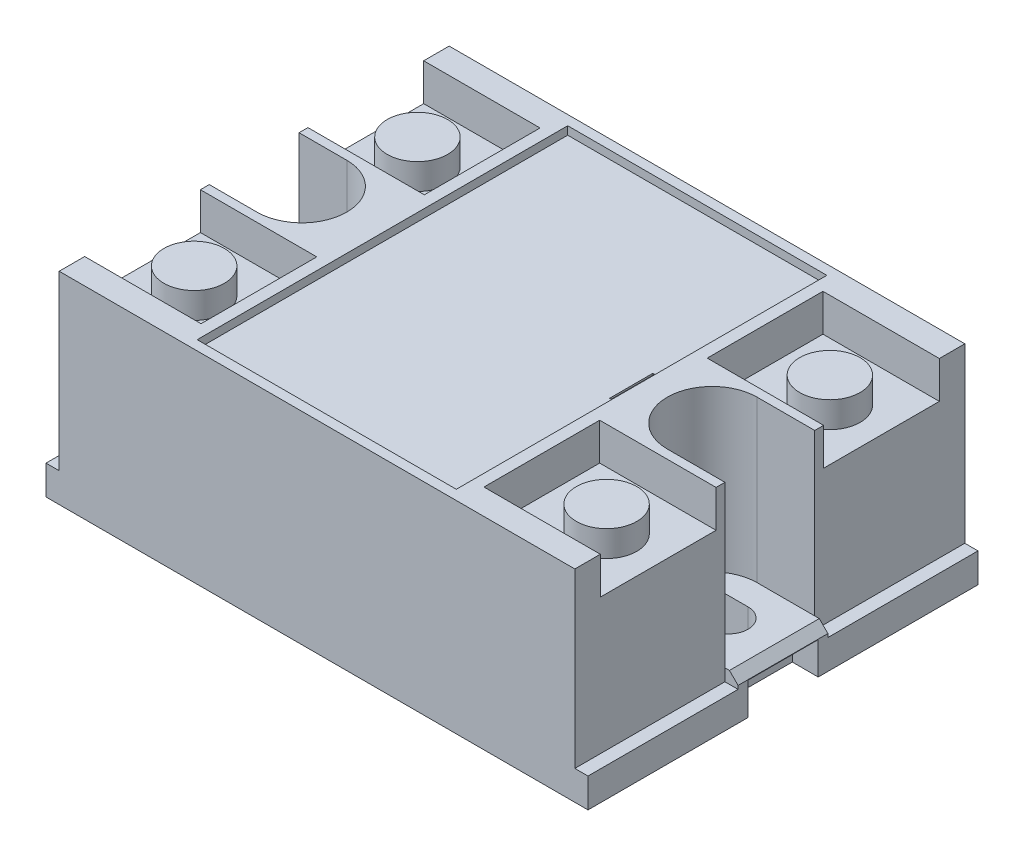
from build123d import *

# Parameters (mm, degrees)
SKETCH1_W                    = 62.75
SKETCH1_H                    = 45.15
BOSS_EXTRUDE1_DEPTH          = 23.4
SKETCH2_W                    = 30
SKETCH2_H                    = 42.9
CUT_EXTRUDE1_DEPTH           = 0.95
SKETCH3_W                    = 15
SKETCH3_H                    = 13.4
CUT_EXTRUDE2_DEPTH           = 4.3
SKETCH4_R                    = 3.5
BOSS_EXTRUDE2_DEPTH          = 3
CUT_EXTRUDE3_DEPTH           = 18.6
SKETCH6_W                    = 0.2
SKETCH6_H                    = 5
CUT_EXTRUDE_THIN1_DEPTH      = 1.95
CUT_EXTRUDE_THIN1_DEPTH_BACK = 1
CUT_EXTRUDE4_DEPTH           = 5.8
SKETCH8_R                    = 2.25
CUT_EXTRUDE5_DEPTH           = 5.8
SKETCH9_W                    = 1.525
SKETCH9_H                    = 45.15
CUT_EXTRUDE6_DEPTH           = 20
SKETCH11_W                   = 1.525
SKETCH11_H                   = 10.4
BOSS_EXTRUDE3_DEPTH          = 1.4
CHAMFER1_SIZE                = 1
SKETCH10_W                   = 3
SKETCH10_H                   = 8.15
CUT_EXTRUDE7_DEPTH           = 3.75


with BuildPart() as part:
    # Sketch1 → Boss-Extrude1 (new body)
    with BuildSketch(Plane(origin=(0, 0, 0), x_dir=(1, 0, 0), z_dir=(0, 1, 0))):
        Rectangle(SKETCH1_W, SKETCH1_H)
    extrude(amount=BOSS_EXTRUDE1_DEPTH)

    # Sketch2 → Cut-Extrude1 (cut)
    with BuildSketch(Plane(origin=(0, 23.4, 0), x_dir=(1, 0, 0), z_dir=(0, 1, 0))):
        Rectangle(SKETCH2_W, SKETCH2_H)
    extrude(amount=-CUT_EXTRUDE1_DEPTH, mode=Mode.SUBTRACT)

    # Sketch3 → Cut-Extrude2 (cut)
    with BuildSketch(Plane(origin=(0, 23.4, 0), x_dir=(1, 0, 0), z_dir=(0, 1, 0))):
        with Locations((-23.875, 12.925)):
            Rectangle(SKETCH3_W, SKETCH3_H)
        with Locations((-23.875, -12.925)):
            Rectangle(SKETCH3_W, SKETCH3_H)
        with Locations((23.875, -12.925)):
            Rectangle(SKETCH3_W, SKETCH3_H)
        with Locations((23.875, 12.925)):
            Rectangle(SKETCH3_W, SKETCH3_H)
    extrude(amount=-CUT_EXTRUDE2_DEPTH, mode=Mode.SUBTRACT)

    # Sketch4 → Boss-Extrude2 (add)
    with BuildSketch(Plane(origin=(0, 19.1, 0), x_dir=(1, 0, 0), z_dir=(0, 1, 0))):
        with Locations((-23.875, 12.925)):
            Circle(SKETCH4_R)
        with Locations((-23.875, -12.925)):
            Circle(SKETCH4_R)
        with Locations((23.875, -12.925)):
            Circle(SKETCH4_R)
        with Locations((23.875, 12.925)):
            Circle(SKETCH4_R)
    extrude(amount=BOSS_EXTRUDE2_DEPTH)

    # Sketch5 → Cut-Extrude3 (cut)
    with BuildSketch(Plane(origin=(0, 23.4, 0), x_dir=(1, 0, 0), z_dir=(0, 1, 0))):
        with BuildLine():
            Line((31.375, -5.2), (23.175, -5.2))
            ThreePointArc((23.175, -5.2), (17.975, 0), (23.175, 5.2))
            Line((23.175, 5.2), (31.375, 5.2))
            ThreePointArc((31.375, 5.2), (36.575, 0), (31.375, -5.2))
        make_face()
        with BuildLine():
            Line((-31.375, 5.2), (-24.325, 5.2))
            ThreePointArc((-24.325, 5.2), (-19.125, 0), (-24.325, -5.2))
            Line((-24.325, -5.2), (-31.375, -5.2))
            ThreePointArc((-31.375, -5.2), (-36.575, 0), (-31.375, 5.2))
        make_face()
    extrude(amount=-CUT_EXTRUDE3_DEPTH, mode=Mode.SUBTRACT)

    # Sketch6 → Cut-Extrude-Thin1 (cut, two sides)
    with BuildSketch(Plane(origin=(0, 22.45, 0), x_dir=(1, 0, 0), z_dir=(0, 1, 0))) as cut_extrude_thin1_sk:
        with Locations((13.9, 0)):
            Rectangle(SKETCH6_W, SKETCH6_H)
    extrude(amount=CUT_EXTRUDE_THIN1_DEPTH, mode=Mode.SUBTRACT)
    extrude(cut_extrude_thin1_sk.sketch, amount=-CUT_EXTRUDE_THIN1_DEPTH_BACK, mode=Mode.SUBTRACT)

    # Sketch7 → Cut-Extrude4 (cut, through all)
    with BuildSketch(Plane(origin=(0, 4.8, 0), x_dir=(1, 0, 0), z_dir=(0, 1, 0))):
        with BuildLine():
            Line((22.275, 2.25), (25.075, 2.25))
            ThreePointArc((25.075, 2.25), (27.325, 0), (25.075, -2.25))
            Line((25.075, -2.25), (22.275, -2.25))
            ThreePointArc((22.275, -2.25), (20.025, 0), (22.275, 2.25))
        make_face()
    extrude(amount=-CUT_EXTRUDE4_DEPTH, mode=Mode.SUBTRACT)

    # Sketch8 → Cut-Extrude5 (cut, through all)
    with BuildSketch(Plane(origin=(0, 4.8, 0), x_dir=(1, 0, 0), z_dir=(0, 1, 0))):
        with Locations((-23.825, 0)):
            Circle(SKETCH8_R)
    extrude(amount=-CUT_EXTRUDE5_DEPTH, mode=Mode.SUBTRACT)

    # Sketch9 → Cut-Extrude6 (cut)
    with BuildSketch(Plane(origin=(0, 23.4, 0), x_dir=(1, 0, 0), z_dir=(0, 1, 0))):
        with Locations((-30.6125, 0)):
            Rectangle(SKETCH9_W, SKETCH9_H)
        with Locations((30.6125, 0)):
            Rectangle(SKETCH9_W, SKETCH9_H)
    extrude(amount=-CUT_EXTRUDE6_DEPTH, mode=Mode.SUBTRACT)

    # Sketch11 → Boss-Extrude3 (add)
    with BuildSketch(Plane(origin=(0, 3.4, 0), x_dir=(1, 0, 0), z_dir=(0, 1, 0))):
        with Locations((-30.6125, 0)):
            Rectangle(SKETCH11_W, SKETCH11_H)
        with Locations((30.6125, 0)):
            Rectangle(SKETCH11_W, SKETCH11_H)
    extrude(amount=BOSS_EXTRUDE3_DEPTH)

    # Chamfer1
    chamfer1_edges = [part.edges().sort_by_distance(p)[0] for p in [
        (-31.375, 4.8, 0),
        (31.375, 4.8, 0),
    ]]
    chamfer(chamfer1_edges, length=CHAMFER1_SIZE)

    # Sketch10 → Cut-Extrude7 (cut)
    with BuildSketch(Plane.XZ):
        with Locations((29.875, 0)):
            Rectangle(SKETCH10_W, SKETCH10_H)
        with Locations((-29.875, 0)):
            Rectangle(SKETCH10_W, SKETCH10_H)
    extrude(amount=-CUT_EXTRUDE7_DEPTH, mode=Mode.SUBTRACT)


solid = part.part
